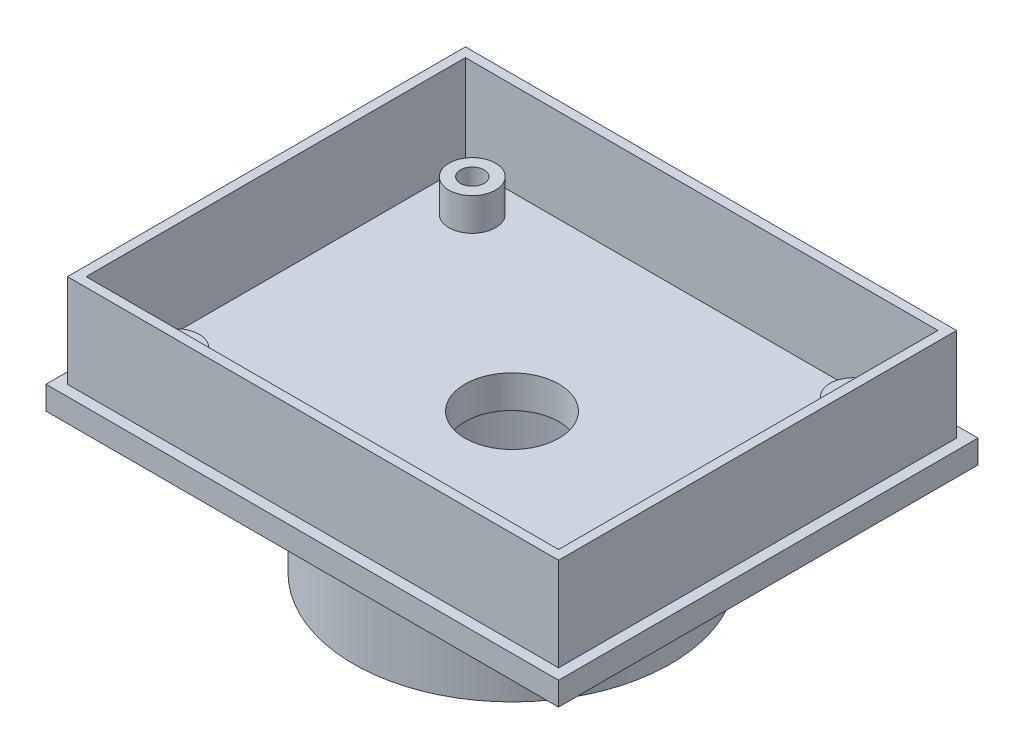
from build123d import *

# Parameters (mm, degrees)
SKETCH1_W           = 110
SKETCH1_H           = 90
BOSS_EXTRUDE1_DEPTH = 5
SKETCH4_W           = 105.4
SKETCH4_H           = 85.4
SKETCH4_W_2         = 101.4
SKETCH4_H_2         = 81.4
BOSS_EXTRUDE2_DEPTH = 20
SKETCH5_R           = 5
BOSS_EXTRUDE3_DEPTH = 7
SKETCH9_R           = 2.524761235
CUT_EXTRUDE1_DEPTH  = 5
SKETCH10_R          = 34
BOSS_EXTRUDE4_DEPTH = 25
SKETCH11_R          = 10.080259213
CUT_EXTRUDE2_DEPTH  = 31
CUT_EXTRUDE3_DEPTH  = 23


with BuildPart() as part:
    # Sketch1 → Boss-Extrude1 (new body)
    with BuildSketch(Plane(origin=(0, 0, 0), x_dir=(1, 0, 0), z_dir=(0, 1, 0))):
        Rectangle(SKETCH1_W, SKETCH1_H)
    extrude(amount=BOSS_EXTRUDE1_DEPTH)

    # Sketch4 → Boss-Extrude2 (add)
    with BuildSketch(Plane(origin=(0, 5, 0), x_dir=(1, 0, 0), z_dir=(0, 1, 0))):
        Rectangle(SKETCH4_W, SKETCH4_H)
        Rectangle(SKETCH4_W_2, SKETCH4_H_2, mode=Mode.SUBTRACT)
    extrude(amount=BOSS_EXTRUDE2_DEPTH)

    # Sketch5 → Boss-Extrude3 (add)
    with BuildSketch(Plane(origin=(0, 5, 0), x_dir=(1, 0, 0), z_dir=(0, 1, 0))):
        with Locations(Location((-40.846907762, 32.318983418, 0), (0, 0, 270))):
            Circle(SKETCH5_R)
        with Locations(Location((-40.846907762, -31.281016582, 0), (0, 0, 270))):
            Circle(SKETCH5_R)
        with Locations(Location((40.953092238, -31.273370815, 0), (0, 0, 270))):
            Circle(SKETCH5_R)
        with Locations(Location((40.953092238, 32.318983418, 0), (0, 0, 270))):
            Circle(SKETCH5_R)
    extrude(amount=BOSS_EXTRUDE3_DEPTH)

    # Sketch9 → Cut-Extrude1 (cut)
    with BuildSketch(Plane(origin=(0, 12, 0), x_dir=(1, 0, 0), z_dir=(0, 1, 0))):
        with Locations(Location((40.953092238, 32.318983418, 0), (0, 0, 270))):
            Circle(SKETCH9_R)
        with Locations(Location((40.953092238, -31.273370815, 0), (0, 0, 270))):
            Circle(SKETCH9_R)
        with Locations(Location((-40.846907762, -31.273370815, 0), (0, 0, 270))):
            Circle(SKETCH9_R)
        with Locations(Location((-40.846907762, 32.318983418, 0), (0, 0, 270))):
            Circle(SKETCH9_R)
    extrude(amount=-CUT_EXTRUDE1_DEPTH, mode=Mode.SUBTRACT)

    # Sketch10 → Boss-Extrude4 (add)
    with BuildSketch(Plane.XZ):
        with Locations(Location((0, 0, 0), (0, 0, 270))):
            Circle(SKETCH10_R)
    extrude(amount=BOSS_EXTRUDE4_DEPTH)

    # Sketch11 → Cut-Extrude2 (cut)
    with BuildSketch(Plane(origin=(0, -25, 0), x_dir=(-1, 0, 0), z_dir=(0, -1, 0))):
        with Locations(Location((0, 0, 0), (0, 0, 90))):
            Circle(SKETCH11_R)
    extrude(amount=-CUT_EXTRUDE2_DEPTH, mode=Mode.SUBTRACT)

    # 3DSketch1 → Cut-Extrude3 (cut)
    with BuildSketch(Plane(origin=(0, -25, -32), x_dir=(-0.004227803372085143, 0, 0.9999910627993868), z_dir=(0, 1, 0))):
        with BuildLine():
            add(Edge.make_bspline(
                [(0, 0), (-0.011789907, 2.799656794), (0.703810307, 8.402918744), (3.921124481, 16.240807355), (9.062436479, 22.975250557), (15.774929183, 28.145163081), (23.599222448, 31.395708592), (31.998932575, 32.504978995), (40.398695895, 31.396113621), (48.223147077, 28.145948653), (54.935885594, 22.976350086), (60.077545593, 16.242187891), (63.295168912, 8.404298627), (64.369120742, 0), (63.224955208, -8.395027888), (59.941927667, -16.205747313), (54.744156701, -22.896695338), (47.988440156, -28.01000158), (40.137094558, -31.194649365), (31.728354863, -32.233260194), (23.338213795, -31.053824953), (15.541353588, -27.737955266), (8.872355042, -22.512245002), (3.841180978, -15.806348738), (0.727018017, -8.127446073), (0.01141332, -2.710231546), (0, 0)],
                knots=[0, 0, 0, 0, 0.041777734, 0.083555145, 0.125332704, 0.167110267, 0.208887828, 0.25066539, 0.292442951, 0.334220512, 0.375998074, 0.417775635, 0.459553197, 0.501330758, 0.543108319, 0.584885881, 0.626663442, 0.668441003, 0.710218565, 0.751996126, 0.793773688, 0.835551249, 0.877328803, 0.919106374, 0.95955671, 1, 1, 1, 1], degree=3))
        make_face()
    extrude(amount=CUT_EXTRUDE3_DEPTH, mode=Mode.SUBTRACT)


solid = part.part
